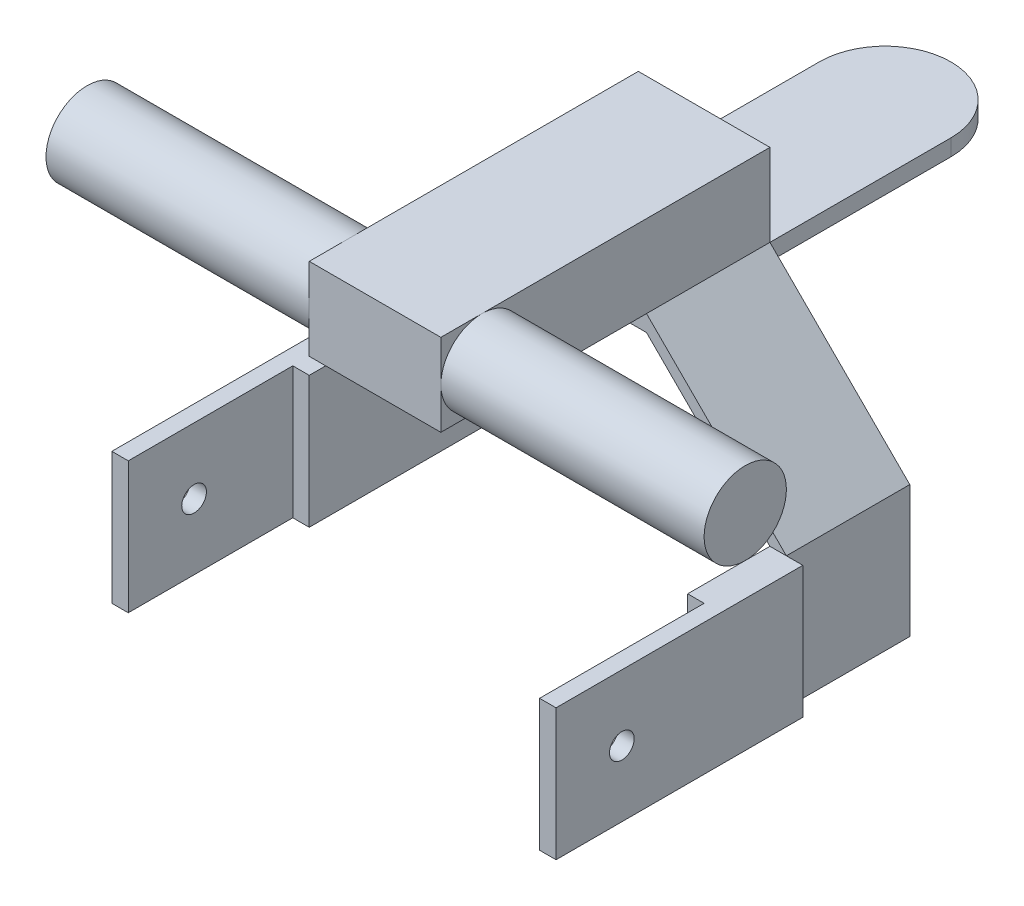
from build123d import *

# Parameters (mm, degrees)
EXTRUDE_1_DEPTH     = 30
SKETCH_2_W          = 32
SKETCH_2_H          = 4
EXTRUDE_2_DEPTH     = 60
CUT_EXTRUDE_1_DEPTH = 30
SKETCH_4_W          = 10
SKETCH_4_H          = 3
EXTRUDE_3_DEPTH     = 16
CUT_EXTRUDE_2_DEPTH = 16
SKETCH_6_W          = 4
SKETCH_6_H          = 32
EXTRUDE_4_DEPTH     = 20
SKETCH_7_W          = 4
SKETCH_7_H          = 60
EXTRUDE_5_DEPTH     = 32
SKETCH_8_R          = 3
CUT_EXTRUDE_3_DEPTH = 109
SKETCH_9_W          = 32
SKETCH_9_H          = 80
EXTRUDE_6_DEPTH     = 20
SKETCH_10_R         = 10
EXTRUDE_7_DEPTH     = 80


with BuildPart() as part:
    # 草图1 → 凸台-拉伸1 (new body)
    with BuildSketch(Plane.XY):
        Polygon((-50, 16), (-16, 50), (16, 50), (50, 16), (50, -16), (46, -16), (46, 16), (16, 46), (-16, 46), (-46, 16), (-46, -16), (-50, -16), align=None)
    extrude(amount=EXTRUDE_1_DEPTH)

    # 草图2 → 凸台-拉伸2 (add)
    with BuildSketch(Plane(origin=(0, 0, 0), x_dir=(-1, 0, 0), z_dir=(0, 0, -1))):
        with Locations((0, 48)):
            Rectangle(SKETCH_2_W, SKETCH_2_H)
    extrude(amount=EXTRUDE_2_DEPTH)

    # 草图3 → 切除-拉伸1 (cut)
    with BuildSketch(Plane(origin=(0, 50, 0), x_dir=(1, 0, 0), z_dir=(0, 1, 0))):
        with BuildLine():
            Line((-16, 44), (-16, 67.226604698))
            Line((-16, 67.226604698), (16, 67.226604698))
            Line((16, 67.226604698), (16, 44))
            ThreePointArc((16, 44), (0, 60), (-16, 44))
        make_face()
    extrude(amount=-CUT_EXTRUDE_1_DEPTH, mode=Mode.SUBTRACT)

    # 草图4 → 凸台-拉伸3 (add)
    with BuildSketch(Plane.ZY.offset(50)):
        with Locations((15, -3.5)):
            Rectangle(SKETCH_4_W, SKETCH_4_H)
        with Locations((15, 3.5)):
            Rectangle(SKETCH_4_W, SKETCH_4_H)
    extrude(amount=EXTRUDE_3_DEPTH)

    # 草图5 → 切除-拉伸2 (cut)
    with BuildSketch(Plane(origin=(0, 5, 0), x_dir=(1, 0, 0), z_dir=(0, 1, 0))):
        with BuildLine():
            Line((-61, -10), (-68.871068814, -10))
            Line((-68.871068814, -10), (-68.871068814, -20.208654659))
            Line((-68.871068814, -20.208654659), (-61, -20.208654659))
            Line((-61, -20.208654659), (-61, -20))
            ThreePointArc((-61, -20), (-66, -15), (-61, -10))
        make_face()
    extrude(amount=-CUT_EXTRUDE_2_DEPTH, mode=Mode.SUBTRACT)

    # 草图6 → 凸台-拉伸4 (add)
    with BuildSketch(Plane.XY.offset(30)):
        with Locations((-48, 0)):
            Rectangle(SKETCH_6_W, SKETCH_6_H)
        with Locations((48, 0)):
            Rectangle(SKETCH_6_W, SKETCH_6_H)
    extrude(amount=EXTRUDE_4_DEPTH)

    # 草图7 → 凸台-拉伸5 (add)
    with BuildSketch(Plane(origin=(0, 16, 0), x_dir=(1, 0, 0), z_dir=(0, 1, 0))):
        with Locations((-52, -60)):
            Rectangle(SKETCH_7_W, SKETCH_7_H)
        with Locations((52, -60)):
            Rectangle(SKETCH_7_W, SKETCH_7_H)
    extrude(amount=-EXTRUDE_5_DEPTH)

    # 草图8 → 切除-拉伸3 (cut, through all)
    with BuildSketch(Plane.ZY.offset(54)):
        with Locations((74, 0)):
            Circle(SKETCH_8_R)
    extrude(amount=-CUT_EXTRUDE_3_DEPTH, mode=Mode.SUBTRACT)

    # 草图9 → 凸台-拉伸6 (add)
    with BuildSketch(Plane(origin=(0, 50, 0), x_dir=(1, 0, 0), z_dir=(0, 1, 0))):
        with Locations((0, -40)):
            Rectangle(SKETCH_9_W, SKETCH_9_H)
    extrude(amount=EXTRUDE_6_DEPTH)

    # 草图10 → 凸台-拉伸7 (add, symmetric)
    with BuildSketch(Plane(origin=(0, 0, 0), x_dir=(0, 0, -1), z_dir=(1, 0, 0))):
        with Locations((-70, 60)):
            Circle(SKETCH_10_R)
    extrude(amount=EXTRUDE_7_DEPTH, both=True)


solid = part.part
